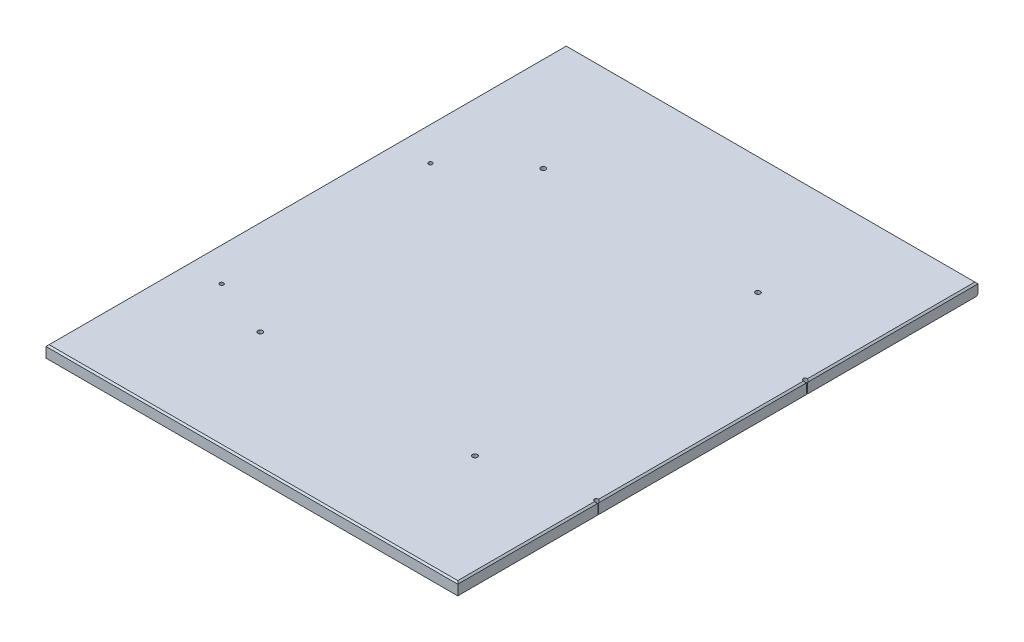
from build123d import *

# Parameters (mm, degrees)
SKETCH1_W           = 669.8488
SKETCH1_H           = 846.328
BOSS_EXTRUDE1_DEPTH = 19.05
CHAMFER1_SIZE       = 2.54
CHAMFER2_SIZE       = 2.54
SKETCH3_R           = 3.96875
CUT_EXTRUDE4_DEPTH  = 20.05
SKETCH2_R           = 3.175
CUT_EXTRUDE3_DEPTH  = 20.05


with BuildPart() as part:
    # Sketch1 → Boss-Extrude1 (new body)
    with BuildSketch(Plane(origin=(0, 0, 0), x_dir=(1, 0, 0), z_dir=(0, 1, 0))):
        with Locations((334.9244, 423.164)):
            Rectangle(SKETCH1_W, SKETCH1_H)
    extrude(amount=BOSS_EXTRUDE1_DEPTH)

    # Chamfer1
    chamfer1_edges = [part.edges().sort_by_distance(p)[0] for p in [
        (669.8488, 19.05, -423.164),
        (334.9244, 19.05, -846.328),
        (0, 19.05, -423.164),
        (334.9244, 19.05, 0),
    ]]
    chamfer(chamfer1_edges, length=CHAMFER1_SIZE)

    # Chamfer2
    chamfer2_edges = [part.edges().sort_by_distance(p)[0] for p in [
        (334.9244, 0, -846.328),
    ]]
    chamfer(chamfer2_edges, length=CHAMFER2_SIZE)

    # Sketch3 → Cut-Extrude4 (cut, through all)
    with BuildSketch(Plane(origin=(0, 19.05, 0), x_dir=(1, 0, 0), z_dir=(0, 1, 0))):
        with Locations((505.58065, 192.283509599)):
            Circle(SKETCH3_R)
        with Locations((156.33065, 192.283509599)):
            Circle(SKETCH3_R)
        with Locations((156.33065, 652.658509599)):
            Circle(SKETCH3_R)
        with Locations((505.58065, 652.658509599)):
            Circle(SKETCH3_R)
    extrude(amount=-CUT_EXTRUDE4_DEPTH, mode=Mode.SUBTRACT)

    # Sketch2 → Cut-Extrude3 (cut, through all)
    with BuildSketch(Plane(origin=(0, 19.05, 0), x_dir=(1, 0, 0), z_dir=(0, 1, 0))):
        with Locations((57.15, 568.325)):
            Circle(SKETCH2_R)
        with Locations((57.15, 228.6)):
            Circle(SKETCH2_R)
        with Locations((666.75, 568.325)):
            Circle(SKETCH2_R)
        with Locations((666.75, 228.6)):
            Circle(SKETCH2_R)
    extrude(amount=-CUT_EXTRUDE3_DEPTH, mode=Mode.SUBTRACT)


solid = part.part
